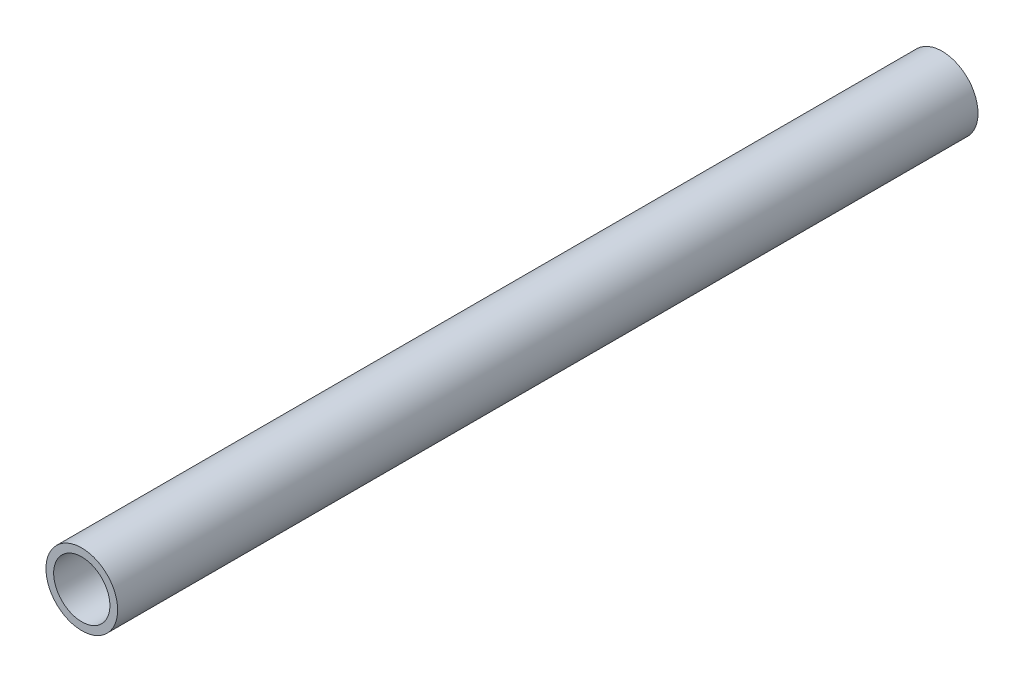
from build123d import *

# Parameters (mm, degrees)
SKETCH1_R           = 13.335
SKETCH1_R_2         = 10.4648
EXTRUDE_THIN1_DEPTH = 160


with BuildPart() as part:
    # Sketch1 → Extrude-Thin1 (new body, symmetric)
    with BuildSketch(Plane.XY):
        Circle(SKETCH1_R)
        Circle(SKETCH1_R_2, mode=Mode.SUBTRACT)
    extrude(amount=EXTRUDE_THIN1_DEPTH, both=True)


solid = part.part
